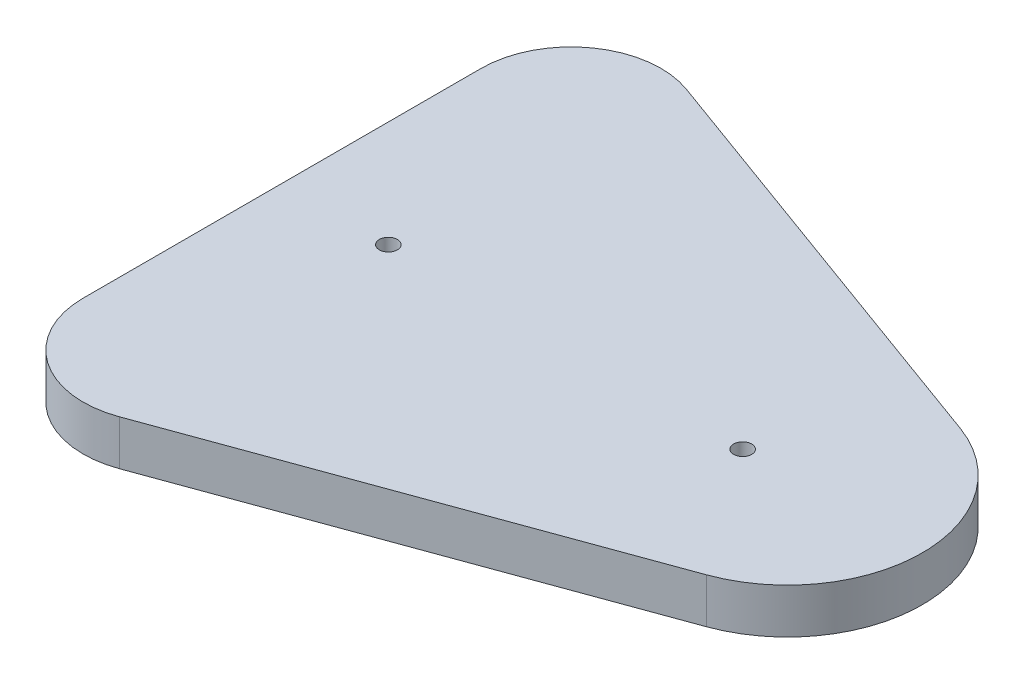
from build123d import *

# Parameters (mm, degrees)
BOSS_EXTRUDE1_DEPTH         = 12.7
F_1_4_20_TAPPED_HOLE1_D     = 5.1054
F_1_4_20_TAPPED_HOLE1_DEPTH = 19.05
F_1_4_20_TAPPED_HOLE1_TIP   = 1.533816902


with BuildPart() as part:
    # Sketch1 → Boss-Extrude1 (new body)
    with BuildSketch(Plane(origin=(0, 0, 0), x_dir=(1, 0, 0), z_dir=(0, 1, 0))):
        with BuildLine():
            Line((8.6875712, -23.868098094), (130.234472266, 20.372852858))
            ThreePointArc((130.234472266, 20.372852858), (155.303115466, 56.175), (130.234472266, 91.977147142))
            Line((130.234472266, 91.977147142), (8.6875712, 136.218098094))
            ThreePointArc((8.6875712, 136.218098094), (-14.568728351, 133.156541141), (-25.4, 112.35))
            Line((-25.4, 112.35), (-25.4, 0))
            ThreePointArc((-25.4, 0), (-14.568728351, -20.806541141), (8.6875712, -23.868098094))
        make_face()
    extrude(amount=BOSS_EXTRUDE1_DEPTH)

    # 1/4-20 Tapped Hole1
    with Locations(Plane(origin=(4.6, 12.7, -56.175), x_dir=(0, 0, 1), z_dir=(0, 1, 0))):
        with Locations((0, 0), (0, 100)):
            Hole(F_1_4_20_TAPPED_HOLE1_D / 2, depth=F_1_4_20_TAPPED_HOLE1_DEPTH)
            with Locations((0, 0, -(F_1_4_20_TAPPED_HOLE1_DEPTH + F_1_4_20_TAPPED_HOLE1_TIP / 2))):  # 118° drill point
                Cone(0, F_1_4_20_TAPPED_HOLE1_D / 2, F_1_4_20_TAPPED_HOLE1_TIP, mode=Mode.SUBTRACT)


solid = part.part
